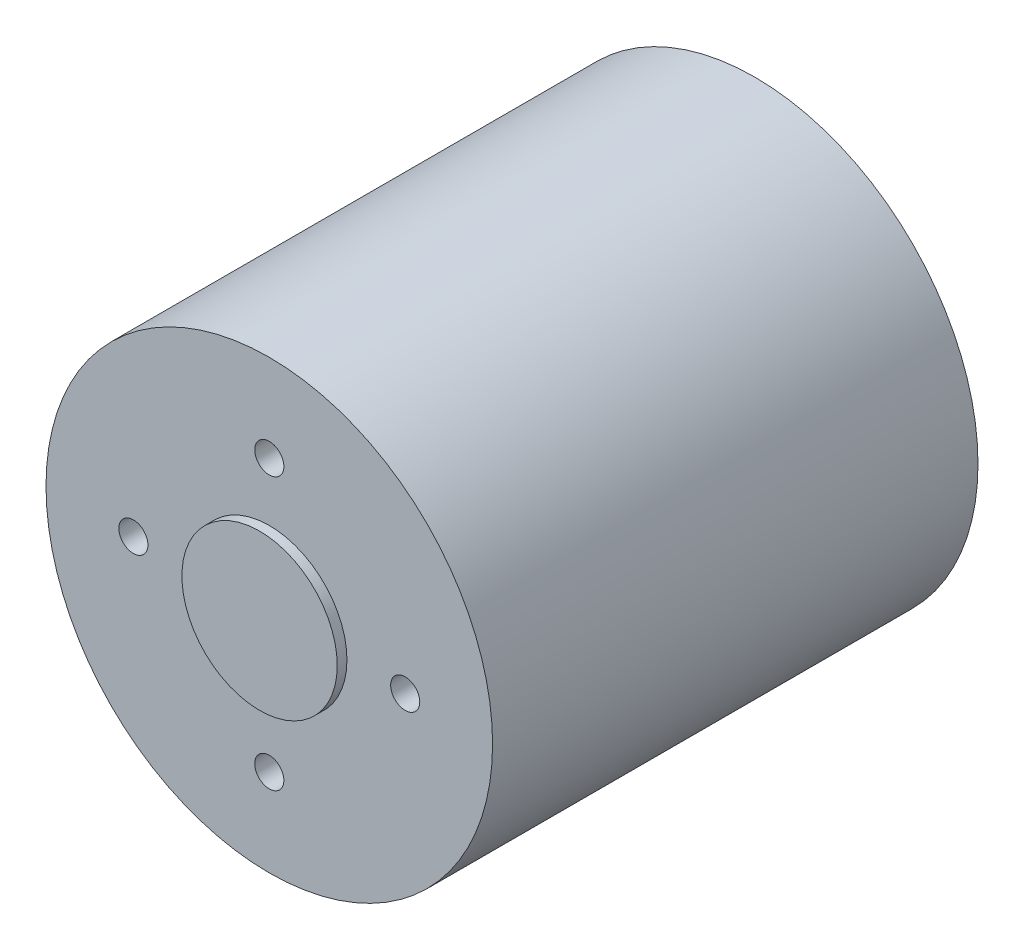
from build123d import *

# Parameters (mm, degrees)
SKETCH1_R           = 23
BOSS_EXTRUDE1_DEPTH = 50
SKETCH2_R           = 8
BOSS_EXTRUDE2_DEPTH = 1
SKETCH5_R           = 1.5
CUT_EXTRUDE2_DEPTH  = 10
SKETCH6_R           = 1.5
CUT_EXTRUDE3_DEPTH  = 5
CIRPATTERN1_COUNT   = 4
CIRPATTERN2_COUNT   = 4
SKETCH7_R           = 5
BOSS_EXTRUDE3_DEPTH = 5
SKETCH8_R           = 2.425
BOSS_EXTRUDE4_DEPTH = 5


with BuildPart() as part:
    # Sketch1 → Boss-Extrude1 (new body)
    with BuildSketch(Plane.XY):
        Circle(SKETCH1_R)
    extrude(amount=-BOSS_EXTRUDE1_DEPTH)

    # Sketch2 → Boss-Extrude2 (add)
    with BuildSketch(Plane.XY):
        Circle(SKETCH2_R)
    extrude(amount=BOSS_EXTRUDE2_DEPTH)

    # Sketch5 → Cut-Extrude2 (cut)
    with BuildSketch(Plane(origin=(0, 0, -50), x_dir=(-1, 0, 0), z_dir=(0, 0, -1))):
        with Locations((-12.5, 0)):
            Circle(SKETCH5_R)
    cut_extrude2 = extrude(amount=-CUT_EXTRUDE2_DEPTH, mode=Mode.SUBTRACT)

    # Sketch6 → Cut-Extrude3 (cut)
    with BuildSketch(Plane.XY):
        with Locations((0, 14)):
            Circle(SKETCH6_R)
    cut_extrude3 = extrude(amount=-CUT_EXTRUDE3_DEPTH, mode=Mode.SUBTRACT)

    # CirPattern1: Cut-Extrude3 ×4 about axis
    cirpattern1_axis = Axis((0, 0, 0), (0, 0, 1))
    for i in range(1, CIRPATTERN1_COUNT):
        add(cut_extrude3.rotate(cirpattern1_axis, i * 360 / CIRPATTERN1_COUNT), mode=Mode.SUBTRACT)

    # CirPattern2: Cut-Extrude2 ×4 about axis
    cirpattern2_axis = Axis((0, 0, 0), (0, 0, 1))
    for i in range(1, CIRPATTERN2_COUNT):
        add(cut_extrude2.rotate(cirpattern2_axis, i * 360 / CIRPATTERN2_COUNT), mode=Mode.SUBTRACT)

    # Sketch7 → Boss-Extrude3 (add)
    with BuildSketch(Plane(origin=(0, 0, -50), x_dir=(-1, 0, 0), z_dir=(0, 0, -1))):
        Circle(SKETCH7_R)
    extrude(amount=BOSS_EXTRUDE3_DEPTH)

    # Sketch8 → Boss-Extrude4 (add)
    with BuildSketch(Plane(origin=(0, 0, -55), x_dir=(-1, 0, 0), z_dir=(0, 0, -1))):
        Circle(SKETCH8_R)
    extrude(amount=BOSS_EXTRUDE4_DEPTH)


solid = part.part
